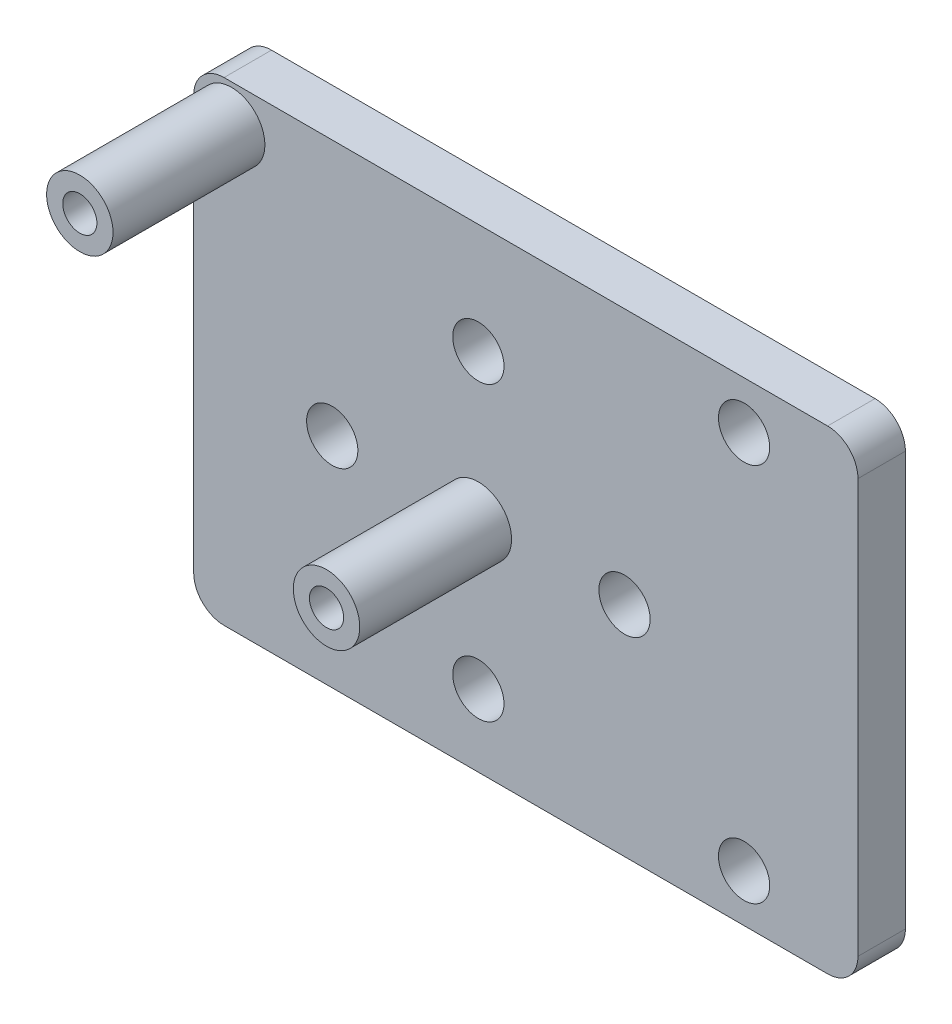
from build123d import *

# Parameters (mm, degrees)
SKETCH1_W           = 44.45
SKETCH1_H           = 31.75
BOSS_EXTRUDE1_DEPTH = 3.175
SKETCH2_R           = 2.2225
SKETCH2_R_2         = 1.143
BOSS_EXTRUDE2_DEPTH = 10.16
SKETCH3_R           = 1.7145
CUT_EXTRUDE1_DEPTH  = 12.7
SKETCH4_R           = 1.7145
CUT_EXTRUDE2_DEPTH  = 12.7
CIRPATTERN1_COUNT   = 4
FILLET1_R           = 2.032


with BuildPart() as part:
    # Sketch1 → Boss-Extrude1 (new body)
    with BuildSketch(Plane.XY):
        with Locations((-22.225, -15.875)):
            Rectangle(SKETCH1_W, SKETCH1_H)
    extrude(amount=BOSS_EXTRUDE1_DEPTH)

    # Sketch2 → Boss-Extrude2 (add)
    with BuildSketch(Plane.XY.offset(3.175)):
        with Locations((-41.91, -2.54)):
            Circle(SKETCH2_R)
        with Locations((-41.91, -2.54)):
            Circle(SKETCH2_R_2, mode=Mode.SUBTRACT)
        with Locations((-25.4, -17.145)):
            Circle(SKETCH2_R)
        with Locations((-25.4, -17.145)):
            Circle(SKETCH2_R_2, mode=Mode.SUBTRACT)
    extrude(amount=BOSS_EXTRUDE2_DEPTH)

    # Sketch3 → Cut-Extrude1 (cut)
    with BuildSketch(Plane.XY.offset(3.175)):
        with Locations((-7.62, -3.175)):
            Circle(SKETCH3_R)
        with Locations((-7.62, -28.575)):
            Circle(SKETCH3_R)
    extrude(amount=-CUT_EXTRUDE1_DEPTH, mode=Mode.SUBTRACT)

    # Sketch4 → Cut-Extrude2 (cut)
    with BuildSketch(Plane.XY.offset(3.175)):
        with Locations((-25.4, -7.366)):
            Circle(SKETCH4_R)
    cut_extrude2 = extrude(amount=-CUT_EXTRUDE2_DEPTH, mode=Mode.SUBTRACT)

    # CirPattern1: Cut-Extrude2 ×4 about axis
    cirpattern1_axis = Axis((-25.4, -17.145, 0), (0, 0, 1))
    for i in range(1, CIRPATTERN1_COUNT):
        add(cut_extrude2.rotate(cirpattern1_axis, i * 360 / CIRPATTERN1_COUNT), mode=Mode.SUBTRACT)

    # Fillet1
    fillet1_edges = [part.edges().sort_by_distance(p)[0] for p in [
        (0, -31.75, 1.5875),
        (-44.45, -31.75, 1.5875),
        (-44.45, 0, 1.5875),
        (0, 0, 1.5875),
    ]]
    fillet(fillet1_edges, radius=FILLET1_R)


solid = part.part
